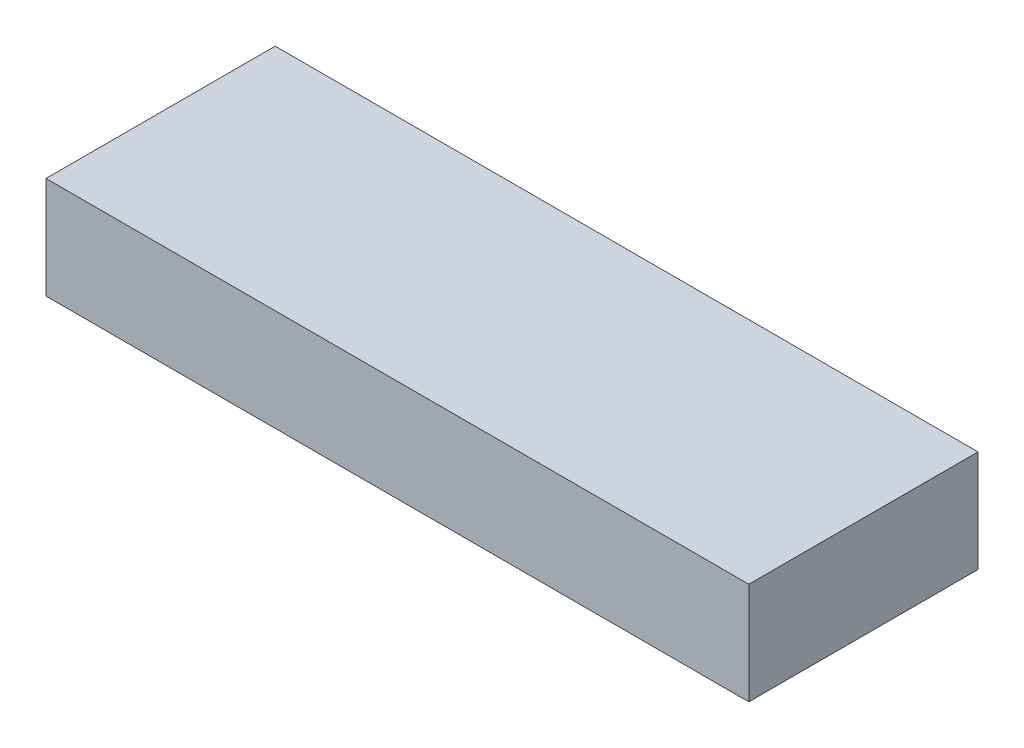
from build123d import *

# Parameters (mm, degrees)
SKETCH1_W           = 138
SKETCH1_H           = 45
BOSS_EXTRUDE1_DEPTH = 20


with BuildPart() as part:
    # Sketch1 → Boss-Extrude1 (new body)
    with BuildSketch(Plane(origin=(0, 0, 0), x_dir=(1, 0, 0), z_dir=(0, 1, 0))):
        with Locations((69, 22.5)):
            Rectangle(SKETCH1_W, SKETCH1_H)
    extrude(amount=BOSS_EXTRUDE1_DEPTH)


solid = part.part
